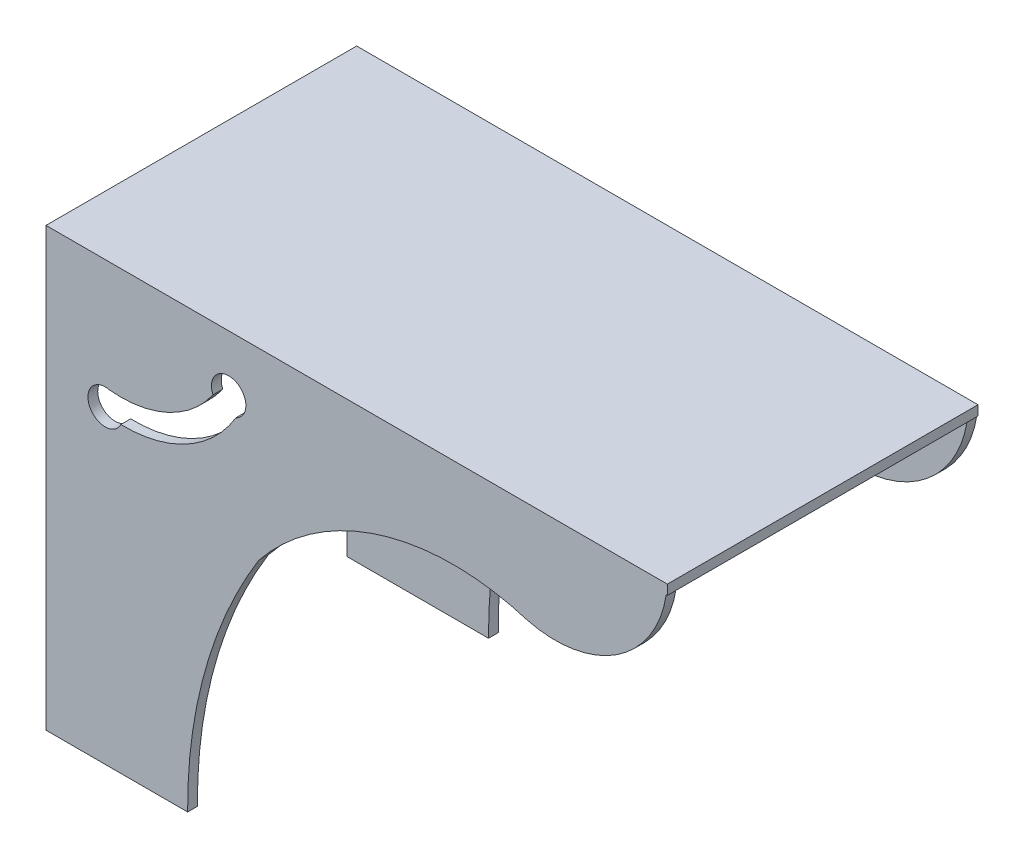
from build123d import *

# Parameters (mm, degrees)
SKETCH1_W           = 63.5
SKETCH1_H           = 31.75
BOSS_EXTRUDE1_DEPTH = 1
BOSS_EXTRUDE2_DEPTH = 1


with BuildPart() as part:
    # Sketch1 → Boss-Extrude1 (new body)
    with BuildSketch(Plane(origin=(0, 0, 0), x_dir=(1, 0, 0), z_dir=(0, 1, 0))):
        Rectangle(SKETCH1_W, SKETCH1_H)
    extrude(amount=BOSS_EXTRUDE1_DEPTH)

    # Sketch2 → Boss-Extrude2 (add)
    with BuildSketch(Plane(origin=(0, 0, -15.875), x_dir=(-1, 0, 0), z_dir=(0, 0, -1))):
        with BuildLine():
            Line((31.75, -17.789177687), (31.75, -43.682471344))
            Line((31.75, -43.682471344), (17.274395694, -43.682471344))
            ThreePointArc((17.274395694, -43.682471344), (15.478784489, -30.222698339), (10.02009663, -17.789177687))
            ThreePointArc((10.02009663, -17.789177687), (-2.413824992, -9.328234834), (-17.453421679, -9.350424234))
            ThreePointArc((-17.453421679, -9.350424234), (-27.026572228, -7.52456476), (-31.75, 1))
            Line((-31.75, 1), (31.75, 1))
            Line((31.75, 1), (31.75, -17.789177687))
        make_face()
        with BuildLine():
            ThreePointArc((14.682172322, -5.461834054), (19.319604518, -9.339676808), (25.284625693, -10.320474532))
            ThreePointArc((25.284625693, -10.320474532), (27.289464402, -12.805118584), (24.096851126, -12.797716819))
            ThreePointArc((24.096851126, -12.797716819), (17.34915582, -11.158394953), (12.353647921, -6.335152376))
            ThreePointArc((12.353647921, -6.335152376), (12.463721653, -3.08771562), (14.682172322, -5.461834054))
        make_face(mode=Mode.SUBTRACT)
    boss_extrude2 = extrude(amount=-BOSS_EXTRUDE2_DEPTH)

    # Mirror1: Boss-Extrude2 across plane
    add(boss_extrude2.mirror(Plane.XY))


solid = part.part
